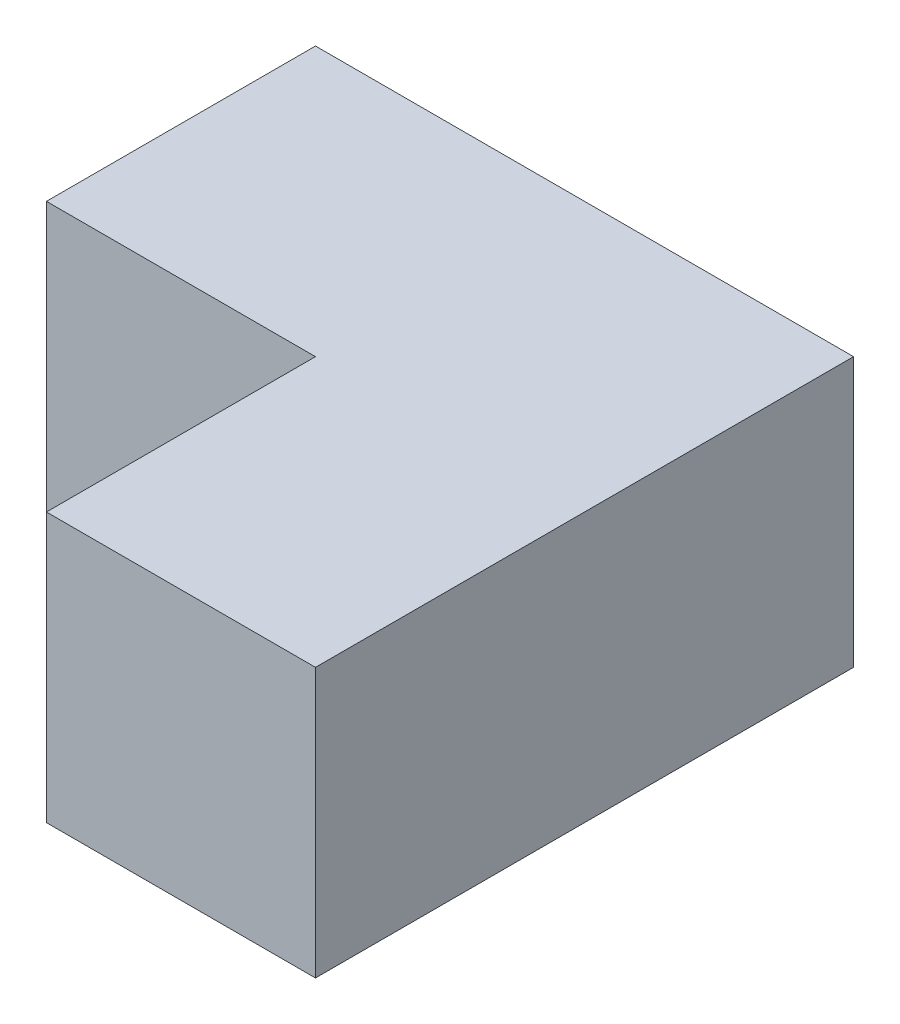
from build123d import *

# Parameters (mm, degrees)
SALIENTE_EXTRUIR1_DEPTH = 200


with BuildPart() as part:
    # Croquis1 → Saliente-Extruir1 (new body)
    with BuildSketch(Plane(origin=(0, 0, 0), x_dir=(1, 0, 0), z_dir=(0, 1, 0))):
        Polygon((400, 200), (400, -200), (200, -200), (200, 0), (0, 0), (0, 200), align=None)
    extrude(amount=SALIENTE_EXTRUIR1_DEPTH)


solid = part.part
